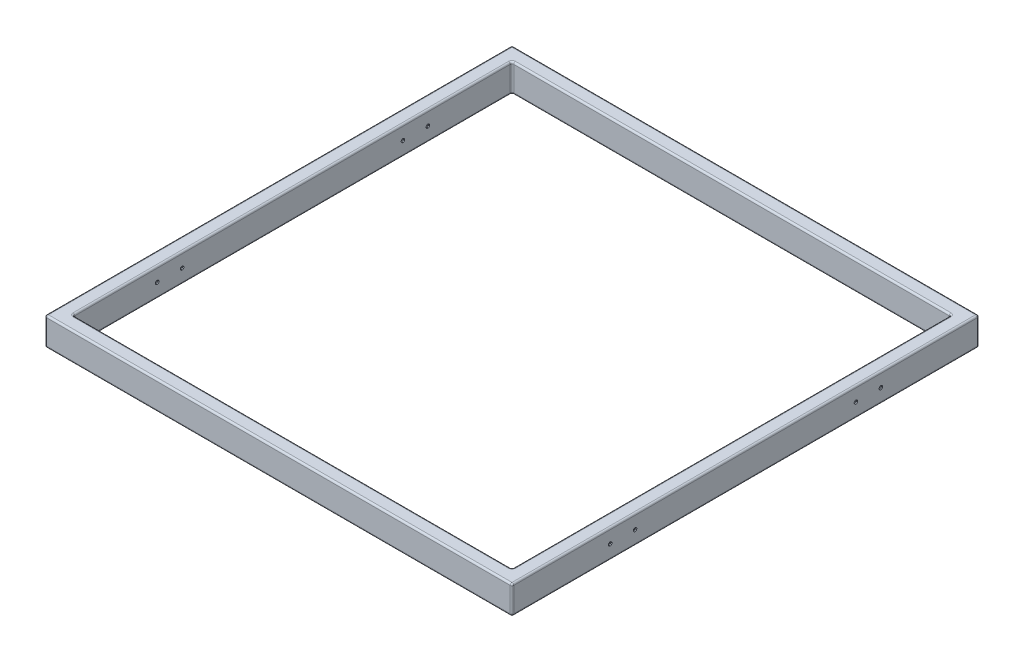
from build123d import *

# Parameters (mm, degrees)
SKETCH1_W           = 1330
SKETCH1_H           = 1330
SKETCH1_W_2         = 1250
SKETCH1_H_2         = 1250
BOSS_EXTRUDE1_DEPTH = 80
FILLET1_R           = 5
SHELL1_T            = 3
SKETCH4_R           = 5
CUT_EXTRUDE1_DEPTH  = 40
SKETCH5_R           = 5
CUT_EXTRUDE2_DEPTH  = 40


with BuildPart() as part:
    # Sketch1 → Boss-Extrude1 (new body)
    with BuildSketch(Plane(origin=(0, 0, 0), x_dir=(1, 0, 0), z_dir=(0, 1, 0))):
        Rectangle(SKETCH1_W, SKETCH1_H)
        Rectangle(SKETCH1_W_2, SKETCH1_H_2, mode=Mode.SUBTRACT)
    extrude(amount=BOSS_EXTRUDE1_DEPTH)

    # Fillet1
    fillet1_edges = [part.edges().sort_by_distance(p)[0] for p in [
        (-665, 80, 0),
        (0, 80, 665),
        (625, 0, 0),
        (625, 40, 625),
        (0, 0, -625),
        (625, 40, -625),
        (-625, 0, 0),
        (-625, 40, -625),
        (0, 0, 625),
        (-625, 40, 625),
        (625, 80, 0),
        (0, 80, -625),
        (-625, 80, 0),
        (0, 80, 625),
        (665, 80, 0),
        (0, 0, 665),
        (-665, 0, 0),
        (0, 0, -665),
        (665, 0, 0),
        (0, 80, -665),
        (665, 40, 665),
        (-665, 40, 665),
        (-665, 40, -665),
        (665, 40, -665),
    ]]
    fillet(fillet1_edges, radius=FILLET1_R)

    # Shell1 (no face opened: a closed hollow body)
    add(offset(amount=-SHELL1_T, mode=Mode.PRIVATE), mode=Mode.SUBTRACT)

    # Sketch4 → Cut-Extrude1 (cut)
    with BuildSketch(Plane.ZY.offset(665)):
        with Locations((385.5, 40)):
            Circle(SKETCH4_R)
        with Locations((314.5, 40)):
            Circle(SKETCH4_R)
        with Locations((-314.5, 40)):
            Circle(SKETCH4_R)
        with Locations((-385.5, 40)):
            Circle(SKETCH4_R)
    extrude(amount=-CUT_EXTRUDE1_DEPTH, mode=Mode.SUBTRACT)

    # Sketch5 → Cut-Extrude2 (cut)
    with BuildSketch(Plane(origin=(665, 0, 0), x_dir=(0, 0, -1), z_dir=(1, 0, 0))):
        with Locations((385.5, 40)):
            Circle(SKETCH5_R)
        with Locations((314.5, 40)):
            Circle(SKETCH5_R)
        with Locations((-314.5, 40)):
            Circle(SKETCH5_R)
        with Locations((-385.5, 40)):
            Circle(SKETCH5_R)
    extrude(amount=-CUT_EXTRUDE2_DEPTH, mode=Mode.SUBTRACT)


solid = part.part
